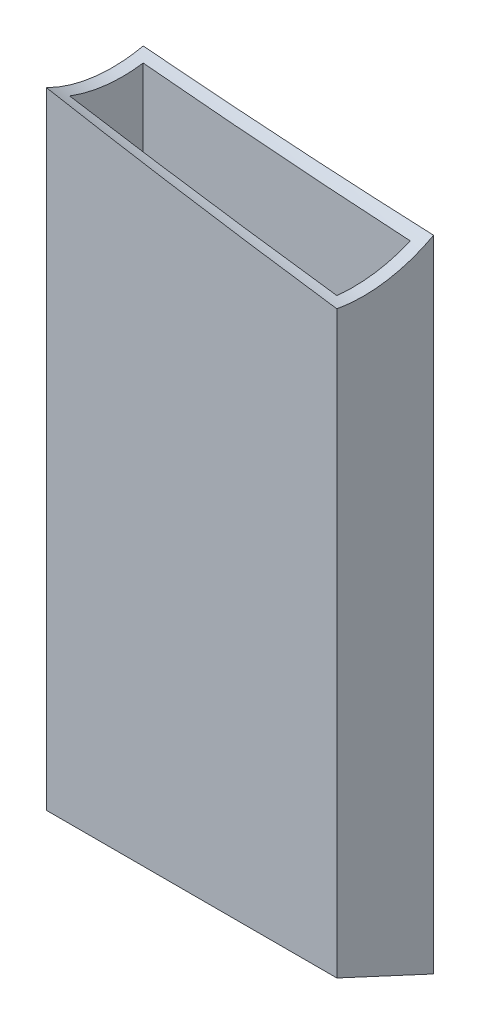
from build123d import *

# Parameters (mm, degrees)
SKETCH1_W           = 76.2
SKETCH1_H           = 25.4
SKETCH1_W_2         = 70.104
SKETCH1_H_2         = 19.304
BOSS_EXTRUDE1_DEPTH = 200
SKETCH3_W           = 76.2
SKETCH3_H           = 25.4
SKETCH3_W_2         = 70.104
SKETCH3_H_2         = 19.304
BOSS_EXTRUDE2_DEPTH = 38.1
CUT_EXTRUDE1_DEPTH  = 77.2
CUT_EXTRUDE2_START  = 13.832764
SKETCH6_R           = 38.1
CUT_EXTRUDE2_DEPTH  = 83.124802


with BuildPart() as part:
    # Sketch1 → Boss-Extrude1 (new body)
    with BuildSketch(Plane(origin=(0, 0, 0), x_dir=(1, 0, 0), z_dir=(0, 1, 0))):
        Rectangle(SKETCH1_W, SKETCH1_H)
        Rectangle(SKETCH1_W_2, SKETCH1_H_2, mode=Mode.SUBTRACT)
    extrude(amount=BOSS_EXTRUDE1_DEPTH)

    # Sketch3 → Boss-Extrude2 (add)
    with BuildSketch(Plane.XZ):
        Rectangle(SKETCH3_W, SKETCH3_H)
        Rectangle(SKETCH3_W_2, SKETCH3_H_2, mode=Mode.SUBTRACT)
    extrude(amount=BOSS_EXTRUDE2_DEPTH)

    # Sketch5 → Cut-Extrude1 (cut, through all)
    with BuildSketch(Plane(origin=(38.1, 0, 0), x_dir=(0, 0, -1), z_dir=(1, 0, 0))):
        Polygon((-27.756394936, -43.348459281), (21.22080401, -61.959922544), (71.342880626, -33.096384918), (0, 0), (-29.237931348, 13.563649542), align=None)
    extrude(amount=-CUT_EXTRUDE1_DEPTH, mode=Mode.SUBTRACT)

    # Sketch6 → Cut-Extrude2 (cut)
    with BuildSketch(Plane(origin=(56.875227758, 193.523427606, 7.656864493), x_dir=(-0.131571603, 0.016382038, 0.991171298), z_dir=(-0.984807753, 0.112143352, -0.132580384)).offset(CUT_EXTRUDE2_START)):
        Circle(SKETCH6_R)
    extrude(amount=CUT_EXTRUDE2_DEPTH, mode=Mode.SUBTRACT)


solid = part.part
